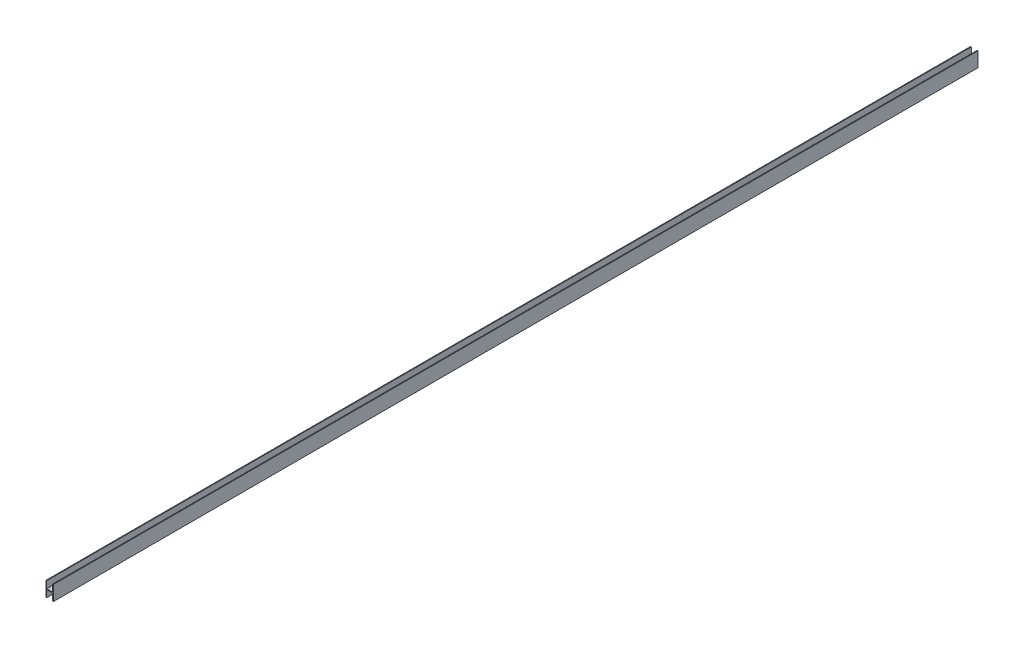
from build123d import *

# Parameters (mm, degrees)
SKETCH_1_W          = 10
SKETCH_1_H          = 20
EXTRUDE_1_DEPTH     = 1251
SKETCH_2_W          = 8
SKETCH_2_H          = 19
CUT_EXTRUDE_1_DEPTH = 2503


with BuildPart() as part:
    # 草图1 → 凸台-拉伸1 (new body)
    with BuildSketch(Plane.XY):
        Rectangle(SKETCH_1_W, SKETCH_1_H)
    extrude(amount=EXTRUDE_1_DEPTH)

    # 草图2 → 切除-拉伸1 (cut)
    with BuildSketch(Plane(origin=(0, 0, 0), x_dir=(-1, 0, 0), z_dir=(0, 0, -1))):
        with Locations((0, 10)):
            Rectangle(SKETCH_2_W, SKETCH_2_H)
        with Locations((0, -10)):
            Rectangle(SKETCH_2_W, SKETCH_2_H)
    extrude(amount=-CUT_EXTRUDE_1_DEPTH, mode=Mode.SUBTRACT)


solid = part.part
